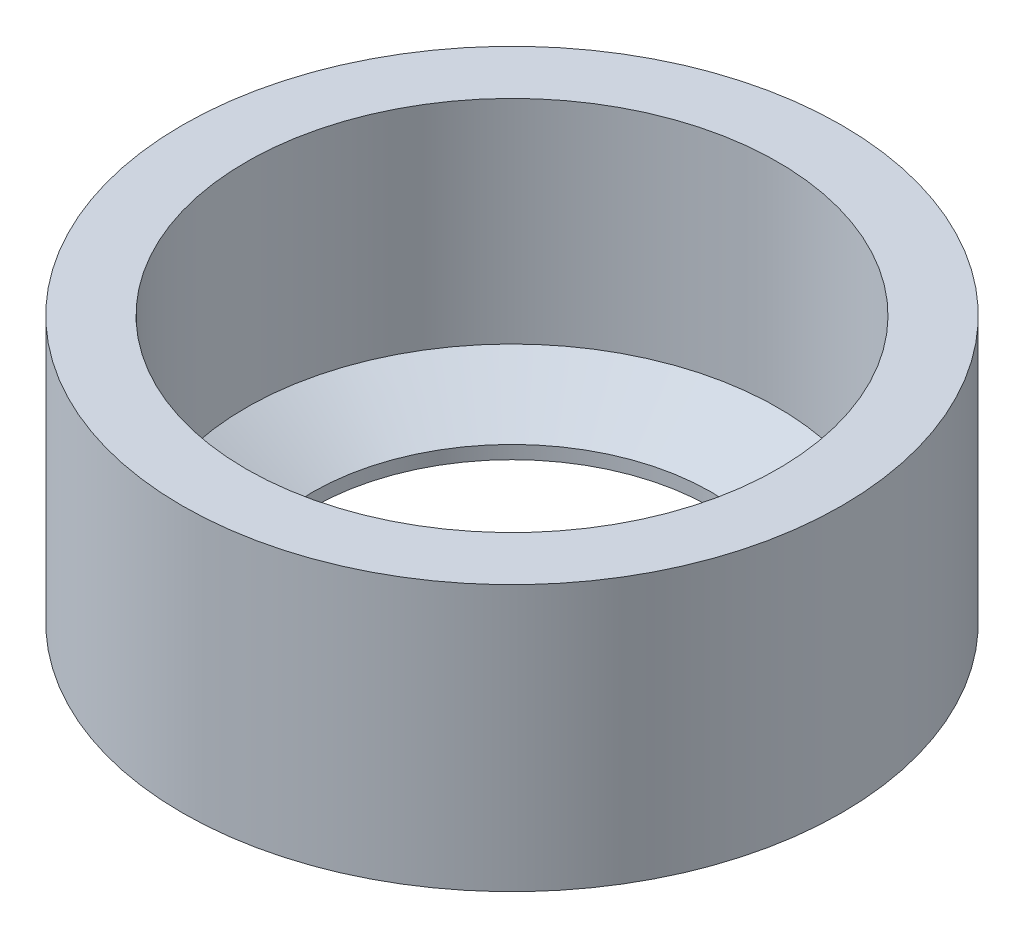
from build123d import *

# Parameters (mm, degrees)
SKETCH1_R                   = 15.748
BOSS_EXTRUDE1_DEPTH         = 12.7
F_1_1_DIAMETER_HOLE1_D      = 25.4
F_1_1_DIAMETER_HOLE1_DEPTH  = 10.16
F_1_1_DIAMETER_HOLE1_TIP    = 7.630929862
F_3_4_0_75_DIAMETER_HOLE1_D = 19.05


with BuildPart() as part:
    # Sketch1 → Boss-Extrude1 (new body)
    with BuildSketch(Plane(origin=(0, 0, 0), x_dir=(1, 0, 0), z_dir=(0, 1, 0))):
        Circle(SKETCH1_R)
    extrude(amount=BOSS_EXTRUDE1_DEPTH)

    # 1 (1) Diameter Hole1
    with Locations(Plane.ZX.offset(12.7)):
        with Locations((0, 0)):
            Hole(F_1_1_DIAMETER_HOLE1_D / 2, depth=F_1_1_DIAMETER_HOLE1_DEPTH)
            with Locations((0, 0, -(F_1_1_DIAMETER_HOLE1_DEPTH + F_1_1_DIAMETER_HOLE1_TIP / 2))):  # 118° drill point
                Cone(0, F_1_1_DIAMETER_HOLE1_D / 2, F_1_1_DIAMETER_HOLE1_TIP, mode=Mode.SUBTRACT)

    # 3/4 (0.75) Diameter Hole1 (through all)
    with Locations(Plane.ZX.offset(12.7)):
        with Locations((0, 0)):
            Hole(F_3_4_0_75_DIAMETER_HOLE1_D / 2)


solid = part.part
